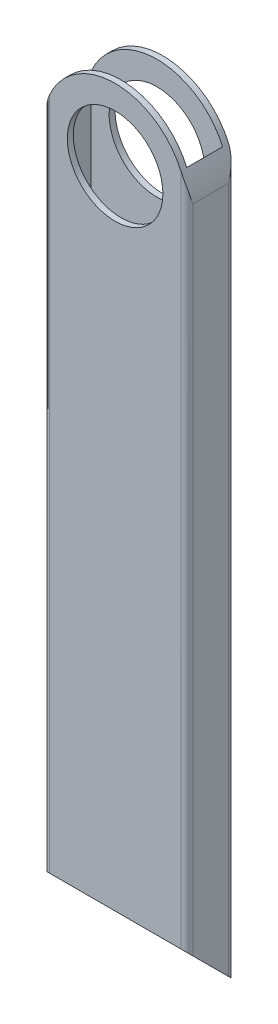
from build123d import *

# Parameters (mm, degrees)
SKETCH1_W           = 34.925
SKETCH1_H           = 9.525
BOSS_EXTRUDE1_DEPTH = 203.2
SKETCH2_R           = 12.7
CUT_EXTRUDE1_DEPTH  = 13.7
CUT_EXTRUDE2_DEPTH  = 39.1000001


with BuildPart() as part:
    # Sketch1 → Boss-Extrude1 (new body)
    with BuildSketch(Plane(origin=(0, 0, 0), x_dir=(1, 0, 0), z_dir=(0, 1, 0))):
        with BuildLine():
            Line((1.5875, 0), (36.5125, 0))
            ThreePointArc((36.5125, 0), (37.635032015, 0.464967985), (38.1, 1.5875))
            Line((38.1, 1.5875), (38.1, 11.1125))
            ThreePointArc((38.1, 11.1125), (37.635032015, 12.235032015), (36.5125, 12.7))
            Line((36.5125, 12.7), (1.5875, 12.7))
            ThreePointArc((1.5875, 12.7), (0.464967985, 12.235032015), (0, 11.1125))
            Line((0, 11.1125), (0, 1.5875))
            ThreePointArc((0, 1.5875), (0.464967985, 0.464967985), (1.5875, 0))
        make_face()
        with Locations((19.05, 6.35)):
            Rectangle(SKETCH1_W, SKETCH1_H, mode=Mode.SUBTRACT)
    extrude(amount=BOSS_EXTRUDE1_DEPTH)

    # Sketch2 → Cut-Extrude1 (cut, through all)
    with BuildSketch(Plane.XY):
        with Locations((19.05, 184.15)):
            Circle(SKETCH2_R)
        with BuildLine():
            Line((0, 184.15), (0, 209.55))
            Line((0, 209.55), (38.1, 209.55))
            Line((38.1, 209.55), (38.1, 184.15))
            ThreePointArc((38.1, 184.15), (19.05, 203.2), (0, 184.15))
        make_face()
    extrude(amount=-CUT_EXTRUDE1_DEPTH, mode=Mode.SUBTRACT)

    # Sketch3 → Cut-Extrude2 (cut, through all)
    with BuildSketch(Plane(origin=(38.1, 0, 0), x_dir=(0, 0, -1), z_dir=(1, 0, 0))):
        Polygon((0, 0), (12.7, 0), (0, 12.7), align=None)
    extrude(amount=-CUT_EXTRUDE2_DEPTH, mode=Mode.SUBTRACT)


solid = part.part
